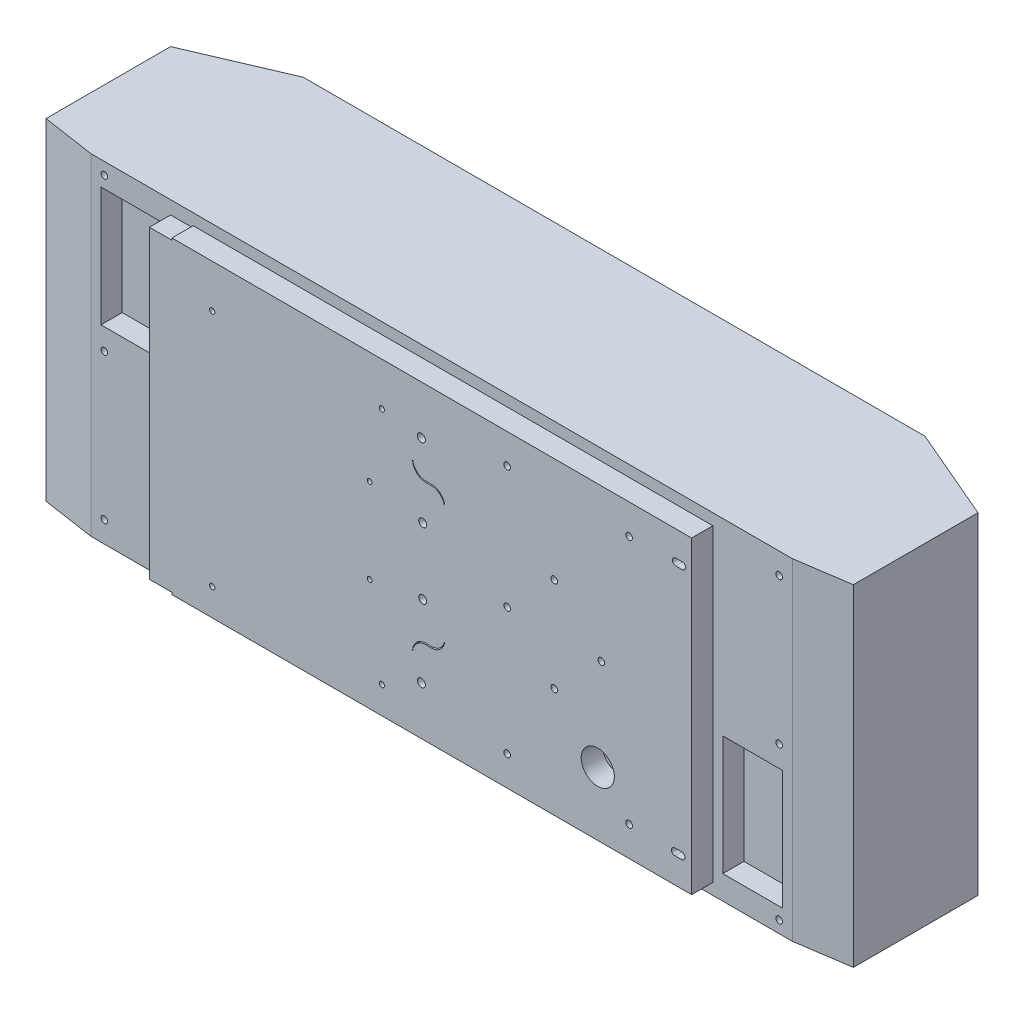
from build123d import *

# Parameters (mm, degrees)
SKETCH_1_R          = 3
SKETCH_1_R_2        = 2
SKETCH_1_R_3        = 1.8
SKETCH_1_R_4        = 2.5
SKETCH_1_R_5        = 12.5
EXTRUDE_1_DEPTH     = 16
SKETCH_9_W          = 529
SKETCH_9_H          = 250
EXTRUDE_2_DEPTH     = 16
SKETCH_10_W         = 45
SKETCH_10_H         = 90
CUT_EXTRUDE_3_DEPTH = 17
EXTRUDE_3_DEPTH     = 250
SKETCH_13_R         = 2.5
CUT_EXTRUDE_4_DEPTH = 17
SKETCH_16_W         = 609
SKETCH_16_H         = 250
EXTRUDE_5_DEPTH     = 114
CUT_EXTRUDE_5_DEPTH = 251


with BuildPart() as part:
    # 草图1 → 凸台-拉伸1 (new body)
    with BuildSketch(Plane.XY):
        with BuildLine():
            Line((17.6, -42.5), (17.6, 42.5))
            ThreePointArc((17.6, 42.5), (14.671067812, 49.571067812), (7.6, 52.5))
            Line((7.6, 52.5), (3.4, 52.5))
            ThreePointArc((3.4, 52.5), (-3.671067812, 55.428932188), (-6.6, 62.5))
            Line((-6.6, 62.5), (-6.6, 116.5))
            Line((-6.6, 116.5), (-188.13, 116.5))
            Line((-188.13, 116.5), (-188.13, 115))
            Line((-188.13, 115), (-205.13, 115))
            Line((-205.13, 115), (-205.13, -115))
            Line((-205.13, -115), (-188.13, -115))
            Line((-188.13, -115), (-188.13, -116.5))
            Line((-188.13, -116.5), (-6.6, -116.5))
            Line((-6.6, -116.5), (-6.6, -62.5))
            ThreePointArc((-6.6, -62.5), (-3.671067812, -55.428932188), (3.4, -52.5))
            Line((3.4, -52.5), (7.6, -52.5))
            ThreePointArc((7.6, -52.5), (14.671067812, -49.571067812), (17.6, -42.5))
        make_face()
        with Locations((1, -25)):
            Circle(SKETCH_1_R, mode=Mode.SUBTRACT)
        with Locations((1, 25)):
            Circle(SKETCH_1_R, mode=Mode.SUBTRACT)
        with Locations((-29.764986182, -95.999990174)):
            Circle(SKETCH_1_R_2, mode=Mode.SUBTRACT)
        with Locations((-157.764986182, -96.000009826)):
            Circle(SKETCH_1_R_2, mode=Mode.SUBTRACT)
        with Locations((-157.764986689, 84.000009826)):
            Circle(SKETCH_1_R_2, mode=Mode.SUBTRACT)
        with Locations((-29.764986689, 83.999990174)):
            Circle(SKETCH_1_R_2, mode=Mode.SUBTRACT)
        with Locations((-39, 32)):
            Circle(SKETCH_1_R_3, mode=Mode.SUBTRACT)
        with Locations((-39, -32)):
            Circle(SKETCH_1_R_3, mode=Mode.SUBTRACT)
        with BuildLine():
            Line((203.87, 116.5), (-6.6, 116.5))
            Line((-6.6, 116.5), (-6.6, 63.5))
            ThreePointArc((-6.6, 63.5), (-3.671067812, 56.428932188), (3.4, 53.5))
            Line((3.4, 53.5), (7.6, 53.5))
            ThreePointArc((7.6, 53.5), (14.671067812, 50.571067812), (17.6, 43.5))
            Line((17.6, 43.5), (17.6, 42.5))
            Line((17.6, 42.5), (17.6, -42.5))
            Line((17.6, -42.5), (17.6, -43.5))
            ThreePointArc((17.6, -43.5), (14.671067812, -50.571067812), (7.6, -53.5))
            Line((7.6, -53.5), (3.4, -53.5))
            ThreePointArc((3.4, -53.5), (-3.671067812, -56.428932188), (-6.6, -63.5))
            Line((-6.6, -63.5), (-6.6, -116.5))
            Line((-6.6, -116.5), (203.87, -116.5))
            Line((203.87, -116.5), (203.87, 116.5))
        make_face()
        with Locations((64.735, -94)):
            Circle(SKETCH_1_R_4, mode=Mode.SUBTRACT)
        with Locations((0, -80)):
            Circle(SKETCH_1_R, mode=Mode.SUBTRACT)
        with Locations((156.735, -94)):
            Circle(SKETCH_1_R_4, mode=Mode.SUBTRACT)
        with BuildLine():
            Line((191.2, -92.28), (196.3, -92.28))
            ThreePointArc((196.3, -92.28), (198.85, -94.83), (196.3, -97.38))
            Line((196.3, -97.38), (191.199998923, -97.38))
            ThreePointArc((191.199998923, -97.38), (188.649998923, -94.829999461), (191.2, -92.28))
        make_face(mode=Mode.SUBTRACT)
        with Locations((133.074292684, -68.663342505)):
            Circle(SKETCH_1_R_5, mode=Mode.SUBTRACT)
        with Locations((100.254601456, -33.676502352)):
            Circle(SKETCH_1_R_4, mode=Mode.SUBTRACT)
        with Locations((64.754601456, 1.823497648)):
            Circle(SKETCH_1_R_4, mode=Mode.SUBTRACT)
        with Locations((100.254601456, 37.323497648)):
            Circle(SKETCH_1_R_4, mode=Mode.SUBTRACT)
        with Locations((135.754601456, 1.823497648)):
            Circle(SKETCH_1_R_4, mode=Mode.SUBTRACT)
        with Locations((0, 80)):
            Circle(SKETCH_1_R, mode=Mode.SUBTRACT)
        with Locations((64.735, 94)):
            Circle(SKETCH_1_R_4, mode=Mode.SUBTRACT)
        with Locations((156.735, 94)):
            Circle(SKETCH_1_R_4, mode=Mode.SUBTRACT)
        with BuildLine():
            Line((191.832821189, 97.371099069), (196.932821189, 97.371099069))
            ThreePointArc((196.932821189, 97.371099069), (199.482821189, 94.821099069), (196.932821189, 92.271099069))
            Line((196.932821189, 92.271099069), (191.832818782, 92.271099069))
            ThreePointArc((191.832818782, 92.271099069), (189.282818782, 94.821100273), (191.832821189, 97.371099069))
        make_face(mode=Mode.SUBTRACT)
    extrude(amount=-EXTRUDE_1_DEPTH)


with BuildPart() as body_2:
    # 草图9 → 凸台-拉伸2 (new body)
    with BuildSketch(Plane(origin=(0, 0, -16), x_dir=(-1, 0, 0), z_dir=(0, 0, -1))):
        with Locations((0.63, 0)):
            Rectangle(SKETCH_9_W, SKETCH_9_H)
    extrude(amount=EXTRUDE_2_DEPTH)

    # 草图10 → 切除-拉伸3 (cut, through all)
    with BuildSketch(Plane.XY.offset(-16)):
        with Locations((-235.13, 62)):
            Rectangle(SKETCH_10_W, SKETCH_10_H)
        with Locations((233.87, -62)):
            Rectangle(SKETCH_10_W, SKETCH_10_H)
    extrude(amount=-CUT_EXTRUDE_3_DEPTH, mode=Mode.SUBTRACT)

    # 草图12 → 凸台-拉伸3 (add)
    with BuildSketch(Plane.XZ.offset(125)):
        Polygon((263.87, -32), (303.87, -32), (303.87, -22), (263.87, -16), align=None)
        Polygon((-265.13, -32), (-305.13, -32), (-305.13, -22), (-265.13, -16), align=None)
    extrude(amount=-EXTRUDE_3_DEPTH)

    # 草图13 → 切除-拉伸4 (cut, through all)
    with BuildSketch(Plane.XY.offset(-16)):
        with Locations((253.87, 109)):
            Circle(SKETCH_13_R)
        with Locations((253.87, -1)):
            Circle(SKETCH_13_R)
        with Locations((-255.13, 1)):
            Circle(SKETCH_13_R)
        with Locations((-255.13, -109)):
            Circle(SKETCH_13_R)
        with Locations((-255.13, 116)):
            Circle(SKETCH_13_R)
        with Locations((253.87, -116)):
            Circle(SKETCH_13_R)
    extrude(amount=-CUT_EXTRUDE_4_DEPTH, mode=Mode.SUBTRACT)

    # 草图16 → 凸台-拉伸5 (add)
    with BuildSketch(Plane(origin=(0, 0, -32), x_dir=(-1, 0, 0), z_dir=(0, 0, -1))):
        with Locations((0.63, 0)):
            Rectangle(SKETCH_16_W, SKETCH_16_H)
    extrude(amount=EXTRUDE_5_DEPTH)

    # 草图17 → 切除-拉伸5 (cut, through all)
    with BuildSketch(Plane(origin=(0, 125, 0), x_dir=(1, 0, 0), z_dir=(0, 1, 0))):
        Polygon((303.87, 116), (233.87, 146), (303.87, 146), align=None)
        Polygon((-305.13, 146), (-305.13, 116), (-235.13, 146), align=None)
    extrude(amount=-CUT_EXTRUDE_5_DEPTH, mode=Mode.SUBTRACT)


solid = Compound([part.part, body_2.part])
